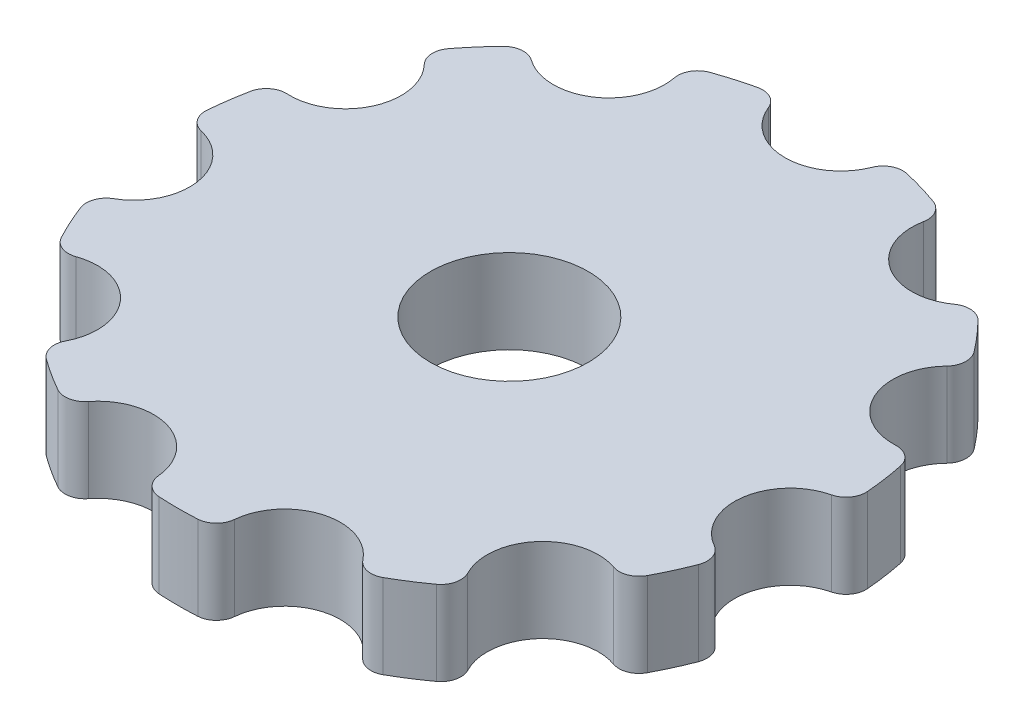
from build123d import *

# Parameters (mm, degrees)
SKETCH1_R           = 2.975
BOSS_EXTRUDE1_DEPTH = 3.175


with BuildPart() as part:
    # Sketch1 → Boss-Extrude1 (new body)
    with BuildSketch(Plane(origin=(0, 0, 0), x_dir=(1, 0, 0), z_dir=(0, 1, 0))):
        with BuildLine():
            ThreePointArc((11.882947492, 0.263140878), (12.316055042, 0.553383075), (12.455331476, 1.055801982))
            ThreePointArc((12.455331476, 1.055801982), (12.372768024, 1.778935478), (12.248256827, 2.4960378))
            ThreePointArc((12.248256827, 2.4960378), (11.973074304, 2.938866505), (11.475739976, 3.095331356))
            ThreePointArc((11.475739976, 3.095331356), (9.460172752, 4.320316135), (9.854306858, 6.645774639))
            ThreePointArc((9.854306858, 6.645774639), (10.061743337, 7.124097533), (9.90728196, 7.622057738))
            ThreePointArc((9.90728196, 7.622057738), (9.446869679, 8.185759174), (8.95442941, 8.721708201))
            ThreePointArc((8.95442941, 8.721708201), (8.483519867, 8.945464509), (7.980544323, 8.80821188))
            ThreePointArc((7.980544323, 8.80821188), (5.622664502, 8.749036741), (4.696993425, 10.918421909))
            ThreePointArc((4.696993425, 10.918421909), (4.612899215, 11.43296136), (4.213740424, 11.768364017))
            ThreePointArc((4.213740424, 11.768364017), (3.521656961, 11.99366217), (2.817633925, 12.178297872))
            ThreePointArc((2.817633925, 12.178297872), (2.300507814, 12.111940737), (1.951582234, 11.724547368))
            ThreePointArc((1.951582234, 11.724547368), (0, 10.4), (-1.951582234, 11.724547368))
            ThreePointArc((-1.951582234, 11.724547368), (-2.300507814, 12.111940737), (-2.817633925, 12.178297872))
            ThreePointArc((-2.817633925, 12.178297872), (-3.521656961, 11.99366217), (-4.213740424, 11.768364017))
            ThreePointArc((-4.213740424, 11.768364017), (-4.612899215, 11.43296136), (-4.696993425, 10.918421909))
            ThreePointArc((-4.696993425, 10.918421909), (-5.622664502, 8.749036741), (-7.980544323, 8.80821188))
            ThreePointArc((-7.980544323, 8.80821188), (-8.483519867, 8.945464509), (-8.95442941, 8.721708201))
            ThreePointArc((-8.95442941, 8.721708201), (-9.446869679, 8.185759174), (-9.90728196, 7.622057738))
            ThreePointArc((-9.90728196, 7.622057738), (-10.061743337, 7.124097533), (-9.854306858, 6.645774639))
            ThreePointArc((-9.854306858, 6.645774639), (-9.460172752, 4.320316135), (-11.475739976, 3.095331356))
            ThreePointArc((-11.475739976, 3.095331356), (-11.973074304, 2.938866505), (-12.248256827, 2.4960378))
            ThreePointArc((-12.248256827, 2.4960378), (-12.372768024, 1.778935478), (-12.455331476, 1.055801982))
            ThreePointArc((-12.455331476, 1.055801982), (-12.316055042, 0.553383075), (-11.882947492, 0.263140878))
            ThreePointArc((-11.882947492, 0.263140878), (-10.294142996, -1.480074318), (-11.327469272, -3.600295003))
            ThreePointArc((-11.327469272, -3.600295003), (-11.661262247, -4.000800849), (-11.653349243, -4.522106966))
            ThreePointArc((-11.653349243, -4.522106966), (-11.370399942, -5.192687663), (-11.048901253, -5.845663444))
            ThreePointArc((-11.048901253, -5.845663444), (-10.660106293, -6.193026599), (-10.138836257, -6.203038252))
            ThreePointArc((-10.138836257, -6.203038252), (-7.859795573, -6.810551633), (-7.582807109, -9.152853138))
            ThreePointArc((-7.582807109, -9.152853138), (-7.647081821, -9.670242202), (-7.358585614, -10.104514722))
            ThreePointArc((-7.358585614, -10.104514722), (-6.758010218, -10.51566916), (-6.13452295, -10.891172029))
            ThreePointArc((-6.13452295, -10.891172029), (-5.619649116, -10.973194086), (-5.175716149, -10.699796566))
            ThreePointArc((-5.175716149, -10.699796566), (-2.930018591, -9.978726926), (-1.430657267, -11.799445071))
            ThreePointArc((-1.430657267, -11.799445071), (-1.205006949, -12.269449983), (-0.727523045, -12.478810449))
            ThreePointArc((-0.727523045, -12.478810449), (0, -12.5), (0.727523045, -12.478810449))
            ThreePointArc((0.727523045, -12.478810449), (1.205006949, -12.269449983), (1.430657267, -11.799445071))
            ThreePointArc((1.430657267, -11.799445071), (2.930018591, -9.978726926), (5.175716149, -10.699796566))
            ThreePointArc((5.175716149, -10.699796566), (5.619649116, -10.973194086), (6.13452295, -10.891172029))
            ThreePointArc((6.13452295, -10.891172029), (6.758010218, -10.51566916), (7.358585614, -10.104514722))
            ThreePointArc((7.358585614, -10.104514722), (7.647081821, -9.670242202), (7.582807109, -9.152853138))
            ThreePointArc((7.582807109, -9.152853138), (7.859795573, -6.810551633), (10.138836257, -6.203038252))
            ThreePointArc((10.138836257, -6.203038252), (10.660106293, -6.193026599), (11.048901253, -5.845663444))
            ThreePointArc((11.048901253, -5.845663444), (11.370399942, -5.192687663), (11.653349243, -4.522106966))
            ThreePointArc((11.653349243, -4.522106966), (11.661262247, -4.000800849), (11.327469272, -3.600295003))
            ThreePointArc((11.327469272, -3.600295003), (10.294142996, -1.480074318), (11.882947492, 0.263140878))
        make_face()
        Circle(SKETCH1_R, mode=Mode.SUBTRACT)
    extrude(amount=BOSS_EXTRUDE1_DEPTH)


solid = part.part
